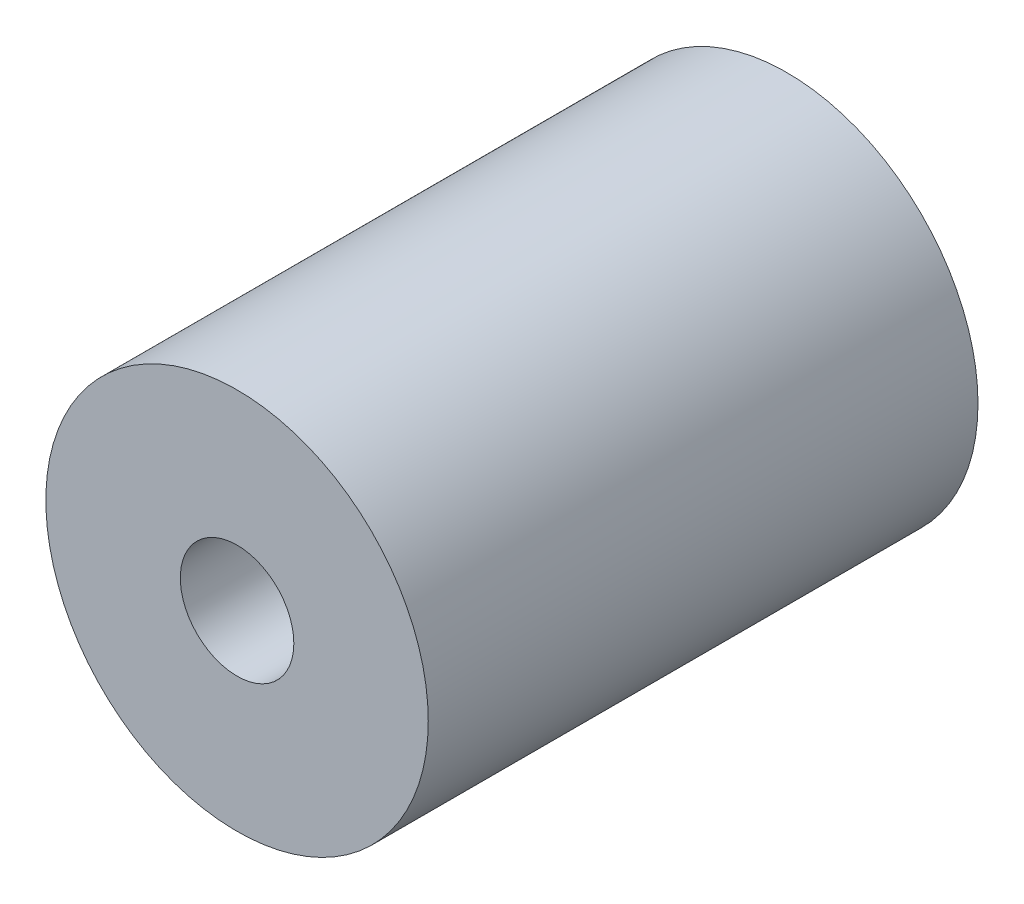
from build123d import *

# Parameters (mm, degrees)
SKETCH1_R           = 8
SKETCH1_R_2         = 2.375
BOSS_EXTRUDE1_DEPTH = 23


with BuildPart() as part:
    # Sketch1 → Boss-Extrude1 (new body)
    with BuildSketch(Plane.XY):
        Circle(SKETCH1_R)
        Circle(SKETCH1_R_2, mode=Mode.SUBTRACT)
    extrude(amount=BOSS_EXTRUDE1_DEPTH)


solid = part.part
